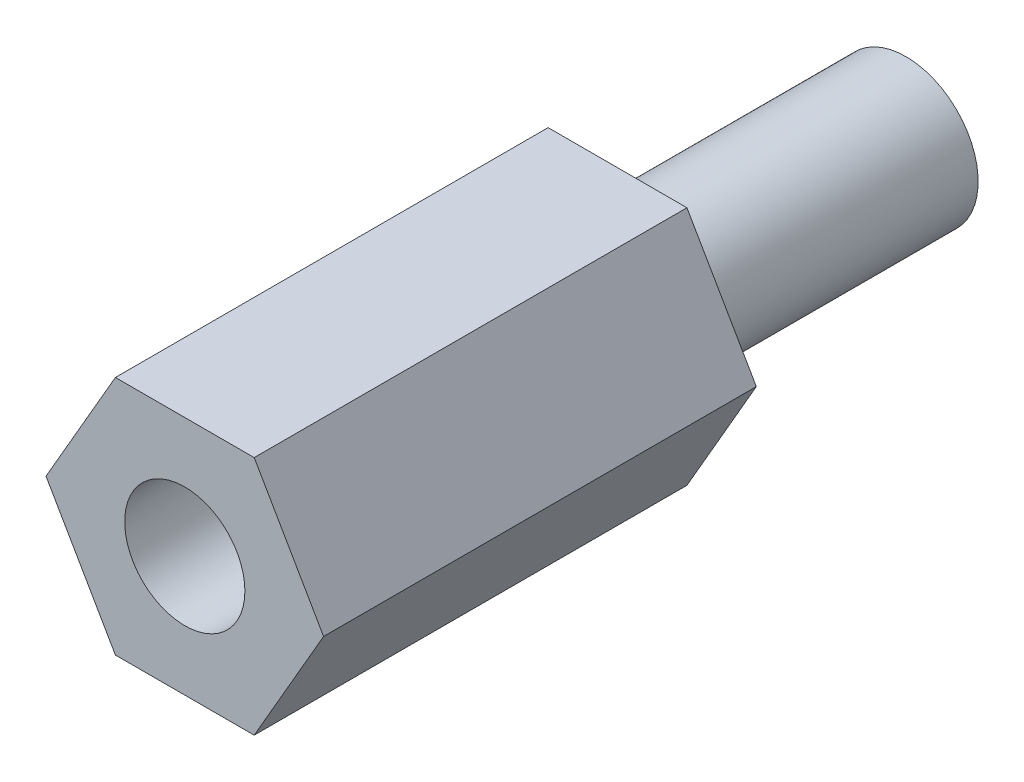
from build123d import *

# Parameters (mm, degrees)
EXTRUDE_1_DEPTH = 9
SKETCH_4_R      = 1.5
EXTRUDE_2_DEPTH = 6
M3X0_5_1_D      = 2.5
M3X0_5_1_DEPTH  = 7.5
M3X0_5_1_TIP    = 0.751075774


with BuildPart() as part:
    # 草圖1 → 填料-伸長1 (new body)
    with BuildSketch(Plane.XY):
        Polygon((-1.443375673, 2.5), (-2.886751346, 0), (-1.443375673, -2.5), (1.443375673, -2.5), (2.886751346, 0), (1.443375673, 2.5), align=None)
    extrude(amount=EXTRUDE_1_DEPTH)

    # 草圖4 → 填料-伸長2 (add)
    with BuildSketch(Plane(origin=(0, 0, 0), x_dir=(-1, 0, 0), z_dir=(0, 0, -1))):
        Circle(SKETCH_4_R)
    extrude(amount=EXTRUDE_2_DEPTH)

    # M3x0.5 螺紋孔1
    with Locations(Plane.XY.offset(9)):
        with Locations((0, 0)):
            Hole(M3X0_5_1_D / 2, depth=M3X0_5_1_DEPTH)
            with Locations((0, 0, -(M3X0_5_1_DEPTH + M3X0_5_1_TIP / 2))):  # 118° drill point
                Cone(0, M3X0_5_1_D / 2, M3X0_5_1_TIP, mode=Mode.SUBTRACT)


solid = part.part
